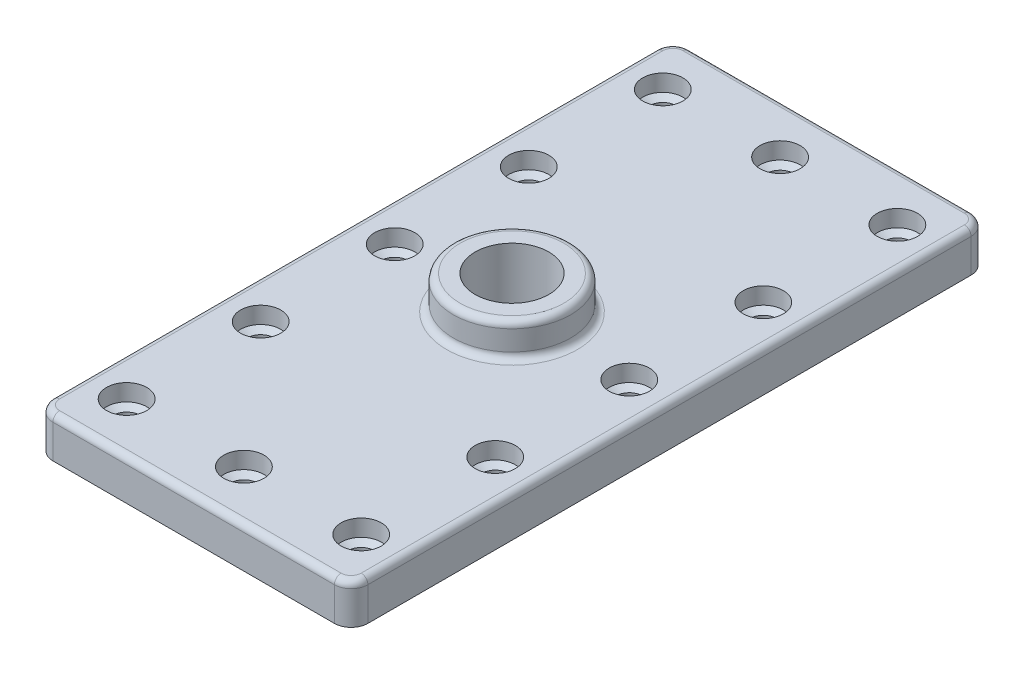
from build123d import *

# Parameters (mm, degrees)
SKETCH1_W            = 94
SKETCH1_H            = 190
PLATE_DEPTH          = 12
SKETCH2_R            = 17.5
BOSS_DEPTH           = 10
SKETCH3_R            = 11
CENTER_HOLE_DEPTH    = 23
FILLET_R5_R          = 5
FILLET_R2_R          = 2
LPATTERN1_COUNT      = 5
LPATTERN1_PITCH      = 40
LPATTERN1_COUNT_DIR2 = 2
LPATTERN1_PITCH_DIR2 = 70
LPATTERN2_COUNT      = 2
LPATTERN2_PITCH      = 35


with BuildPart() as part:
    # Sketch1 → plate (new body)
    with BuildSketch(Plane(origin=(0, 0, 0), x_dir=(1, 0, 0), z_dir=(0, 1, 0))):
        Rectangle(SKETCH1_W, SKETCH1_H)
    extrude(amount=PLATE_DEPTH)

    # Sketch2 → boss (add)
    with BuildSketch(Plane(origin=(0, 12, 0), x_dir=(-1, 0, 0), z_dir=(0, 1, 0))):
        Circle(SKETCH2_R)
    extrude(amount=BOSS_DEPTH)

    # Sketch3 → center hole (cut, through all)
    with BuildSketch(Plane(origin=(0, 22, 0), x_dir=(-1, 0, 0), z_dir=(0, 1, 0))):
        Circle(SKETCH3_R)
    extrude(amount=-CENTER_HOLE_DEPTH, mode=Mode.SUBTRACT)

    # Sketch4 → pattern hole (revolve, cut)
    with BuildSketch(Plane(origin=(-35, 12, 80), x_dir=(0, 0, 1), z_dir=(1, 0, 0))):
        Polygon((0, 0), (0, 12), (4, 12), (4, 6.201721238), (6, 5), (6, 0), align=None)
    pattern_hole = revolve(axis=Axis((-35, 18.130023899, 80), (0, -1, 0)), mode=Mode.SUBTRACT)

    # Fillet R5
    fillet_r5_edges = [part.edges().sort_by_distance(p)[0] for p in [
        (-47, 6, -95),
        (47, 6, -95),
        (47, 6, 95),
        (-47, 6, 95),
    ]]
    fillet(fillet_r5_edges, radius=FILLET_R5_R)

    # Fillet R2
    fillet_r2_edges = [part.edges().sort_by_distance(p)[0] for p in [
        (17.5, 12, 0),
        (17.5, 22, 0),
        (47, 12, 0),
        (0, 12, 95),
        (-47, 12, 0),
        (0, 12, -95),
        (45.535533906, 12, -93.535533906),
        (-45.535533906, 12, -93.535533906),
        (-45.535533906, 12, 93.535533906),
        (45.535533906, 12, 93.535533906),
    ]]
    fillet(fillet_r2_edges, radius=FILLET_R2_R)

    # LPattern1: pattern hole 5 × 2
    with Locations(*[(j * LPATTERN1_PITCH_DIR2, 0, -i * LPATTERN1_PITCH) for i in range(LPATTERN1_COUNT) for j in range(LPATTERN1_COUNT_DIR2) if (i, j) != (0, 0)]):
        add(pattern_hole, mode=Mode.SUBTRACT)

    # LPattern2: pattern hole ×2
    with Locations(*[(i * LPATTERN2_PITCH, 0, 0) for i in range(1, LPATTERN2_COUNT)]):
        add(pattern_hole, mode=Mode.SUBTRACT)

    # LPattern3 copy 1 sketch → LPattern3 copy 1 (revolve, cut)
    with BuildSketch(Plane(origin=(0, 12, -80), x_dir=(0, 0, 1), z_dir=(1, 0, 0))):
        Polygon((0, 0), (0, 12), (4, 12), (4, 6.201721238), (6, 5), (6, 0), align=None)
    revolve(axis=Axis((0, 18.130023899, -80), (0, -1, 0)), mode=Mode.SUBTRACT)

    # LPattern3 copy 2 sketch → LPattern3 copy 2 (revolve, cut)
    with BuildSketch(Plane(origin=(-35, 12, -80), x_dir=(0, 0, 1), z_dir=(1, 0, 0))):
        Polygon((0, 0), (0, 12), (4, 12), (4, 6.201721238), (6, 5), (6, 0), align=None)
    revolve(axis=Axis((-35, 18.130023899, -80), (0, -1, 0)), mode=Mode.SUBTRACT)


solid = part.part
